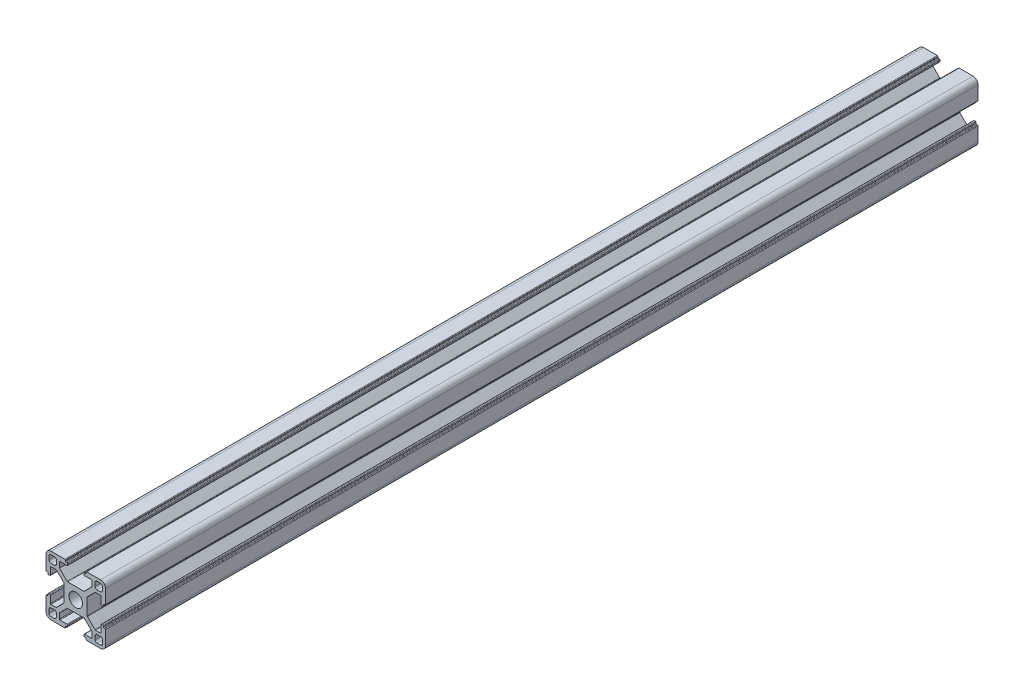
from build123d import *

# Parameters (mm, degrees)
MODEL_R         = 3.4
EXTRUDE_1_DEPTH = 440


with BuildPart() as part:
    # Model → 凸台-拉伸1 (new body)
    with BuildSketch(Plane.XY):
        with BuildLine():
            Line((127.095254839, 55.182120766), (118.855052814, 55.182120766))
            ThreePointArc((118.855052814, 55.182120766), (118.740247784, 55.204956906), (118.64292078, 55.269988732))
            Line((118.64292078, 55.269988732), (114.813021792, 59.099887719))
            ThreePointArc((114.813021792, 59.099887719), (114.747989967, 59.197214724), (114.725153827, 59.312019753))
            Line((114.725153827, 59.312019753), (114.725153827, 61.882120766))
            ThreePointArc((114.725153827, 61.882120766), (114.813021792, 62.0942528), (115.025153827, 62.182120766))
            Line((115.025153827, 62.182120766), (118.575153827, 62.182120766))
            ThreePointArc((118.575153827, 62.182120766), (118.787285861, 62.269988732), (118.875153827, 62.482120766))
            Line((118.875153827, 62.482120766), (118.875153827, 63.082120766))
            ThreePointArc((118.875153827, 63.082120766), (118.787285861, 63.2942528), (118.575153827, 63.382120766))
            Line((118.575153827, 63.382120766), (118.075153827, 63.382120766))
            ThreePointArc((118.075153827, 63.382120766), (117.863021792, 63.469988732), (117.775153827, 63.682120766))
            Line((117.775153827, 63.682120766), (117.775153827, 64.082120766))
            ThreePointArc((117.775153827, 64.082120766), (117.687285861, 64.294252801), (117.475153827, 64.382120766))
            Line((117.475153827, 64.382120766), (110.475153827, 64.382120766))
            ThreePointArc((110.475153827, 64.382120766), (108.707386874, 63.649887719), (107.975153827, 61.882120766))
            Line((107.975153827, 61.882120766), (107.975153827, 54.882120766))
            ThreePointArc((107.975153827, 54.882120766), (108.063021792, 54.669988732), (108.275153827, 54.582120766))
            Line((108.275153827, 54.582120766), (108.675153827, 54.582120766))
            ThreePointArc((108.675153827, 54.582120766), (108.887285861, 54.4942528), (108.975153827, 54.282120766))
            Line((108.975153827, 54.282120766), (108.975153827, 53.782120766))
            ThreePointArc((108.975153827, 53.782120766), (109.063021792, 53.569988732), (109.275153827, 53.482120766))
            Line((109.275153827, 53.482120766), (109.875153827, 53.482120766))
            ThreePointArc((109.875153827, 53.482120766), (110.087285861, 53.569988732), (110.175153827, 53.782120766))
            Line((110.175153827, 53.782120766), (110.175153827, 57.332120766))
            ThreePointArc((110.175153827, 57.332120766), (110.263021792, 57.5442528), (110.475153827, 57.632120766))
            Line((110.475153827, 57.632120766), (113.04525484, 57.632120766))
            ThreePointArc((113.04525484, 57.632120766), (113.160059869, 57.609284626), (113.257386874, 57.5442528))
            Line((113.257386874, 57.5442528), (117.087285861, 53.714353813))
            ThreePointArc((117.087285861, 53.714353813), (117.152317686, 53.617026808), (117.175153827, 53.502221779))
            Line((117.175153827, 53.502221779), (117.175153827, 45.262019753))
            ThreePointArc((117.175153827, 45.262019753), (117.152317686, 45.147214724), (117.087285861, 45.049887719))
            Line((117.087285861, 45.049887719), (113.257386874, 41.219988732))
            ThreePointArc((113.257386874, 41.219988732), (113.160059869, 41.154956907), (113.04525484, 41.132120766))
            Line((113.04525484, 41.132120766), (110.475153827, 41.132120766))
            ThreePointArc((110.475153827, 41.132120766), (110.263021792, 41.219988732), (110.175153827, 41.432120766))
            Line((110.175153827, 41.432120766), (110.175153827, 44.982120766))
            ThreePointArc((110.175153827, 44.982120766), (110.087285861, 45.1942528), (109.875153827, 45.282120766))
            Line((109.875153827, 45.282120766), (109.275153827, 45.282120766))
            ThreePointArc((109.275153827, 45.282120766), (109.063021792, 45.1942528), (108.975153827, 44.982120766))
            Line((108.975153827, 44.982120766), (108.975153827, 44.482120766))
            ThreePointArc((108.975153827, 44.482120766), (108.887285861, 44.269988732), (108.675153827, 44.182120766))
            Line((108.675153827, 44.182120766), (108.275153827, 44.182120766))
            ThreePointArc((108.275153827, 44.182120766), (108.063021792, 44.0942528), (107.975153827, 43.882120766))
            Line((107.975153827, 43.882120766), (107.975153827, 36.882120766))
            ThreePointArc((107.975153827, 36.882120766), (108.707386874, 35.114353813), (110.475153827, 34.382120766))
            Line((110.475153827, 34.382120766), (117.475153827, 34.382120766))
            ThreePointArc((117.475153827, 34.382120766), (117.687285861, 34.469988732), (117.775153827, 34.682120766))
            Line((117.775153827, 34.682120766), (117.775153827, 35.082120766))
            ThreePointArc((117.775153827, 35.082120766), (117.863021792, 35.2942528), (118.075153827, 35.382120766))
            Line((118.075153827, 35.382120766), (118.575153827, 35.382120766))
            ThreePointArc((118.575153827, 35.382120766), (118.787285861, 35.469988732), (118.875153827, 35.682120766))
            Line((118.875153827, 35.682120766), (118.875153827, 36.282120766))
            ThreePointArc((118.875153827, 36.282120766), (118.787285861, 36.4942528), (118.575153827, 36.582120766))
            Line((118.575153827, 36.582120766), (115.025153827, 36.582120766))
            ThreePointArc((115.025153827, 36.582120766), (114.813021792, 36.669988732), (114.725153827, 36.882120766))
            Line((114.725153827, 36.882120766), (114.725153827, 39.452221779))
            ThreePointArc((114.725153827, 39.452221779), (114.747989967, 39.567026809), (114.813021792, 39.664353813))
            Line((114.813021792, 39.664353813), (118.64292078, 43.4942528))
            ThreePointArc((118.64292078, 43.4942528), (118.740247784, 43.559284626), (118.855052814, 43.582120766))
            Line((118.855052814, 43.582120766), (127.095254839, 43.582120766))
            ThreePointArc((127.095254839, 43.582120766), (127.210059869, 43.559284626), (127.307386874, 43.4942528))
            Line((127.307386874, 43.4942528), (131.137285861, 39.664353813))
            ThreePointArc((131.137285861, 39.664353813), (131.202317686, 39.567026809), (131.225153827, 39.452221779))
            Line((131.225153827, 39.452221779), (131.225153827, 36.882120766))
            ThreePointArc((131.225153827, 36.882120766), (131.137285861, 36.669988732), (130.925153827, 36.582120766))
            Line((130.925153827, 36.582120766), (127.375153827, 36.582120766))
            ThreePointArc((127.375153827, 36.582120766), (127.163021792, 36.4942528), (127.075153827, 36.282120766))
            Line((127.075153827, 36.282120766), (127.075153827, 35.682120766))
            ThreePointArc((127.075153827, 35.682120766), (127.163021792, 35.469988732), (127.375153827, 35.382120766))
            Line((127.375153827, 35.382120766), (127.875153827, 35.382120766))
            ThreePointArc((127.875153827, 35.382120766), (128.087285861, 35.2942528), (128.175153827, 35.082120766))
            Line((128.175153827, 35.082120766), (128.175153827, 34.682120766))
            ThreePointArc((128.175153827, 34.682120766), (128.263021792, 34.469988732), (128.475153826, 34.382120766))
            Line((128.475153826, 34.382120766), (135.475153827, 34.382120766))
            ThreePointArc((135.475153827, 34.382120766), (137.24292078, 35.114353813), (137.975153827, 36.882120766))
            Line((137.975153827, 36.882120766), (137.975153827, 43.882120766))
            ThreePointArc((137.975153827, 43.882120766), (137.887285861, 44.0942528), (137.675153827, 44.182120766))
            Line((137.675153827, 44.182120766), (137.275153827, 44.182120766))
            ThreePointArc((137.275153827, 44.182120766), (137.063021792, 44.269988732), (136.975153827, 44.482120766))
            Line((136.975153827, 44.482120766), (136.975153827, 44.982120766))
            ThreePointArc((136.975153827, 44.982120766), (136.887285861, 45.1942528), (136.675153827, 45.282120766))
            Line((136.675153827, 45.282120766), (136.075153827, 45.282120766))
            ThreePointArc((136.075153827, 45.282120766), (135.863021792, 45.1942528), (135.775153827, 44.982120766))
            Line((135.775153827, 44.982120766), (135.775153827, 41.432120766))
            ThreePointArc((135.775153827, 41.432120766), (135.687285861, 41.219988732), (135.475153827, 41.132120766))
            Line((135.475153827, 41.132120766), (132.905052814, 41.132120766))
            ThreePointArc((132.905052814, 41.132120766), (132.790247784, 41.154956907), (132.692920779, 41.219988732))
            Line((132.692920779, 41.219988732), (128.863021792, 45.049887719))
            ThreePointArc((128.863021792, 45.049887719), (128.797989967, 45.147214724), (128.775153827, 45.262019753))
            Line((128.775153827, 45.262019753), (128.775153827, 53.502221779))
            ThreePointArc((128.775153827, 53.502221779), (128.797989967, 53.617026808), (128.863021792, 53.714353813))
            Line((128.863021792, 53.714353813), (132.692920779, 57.5442528))
            ThreePointArc((132.692920779, 57.5442528), (132.790247784, 57.609284626), (132.905052814, 57.632120766))
            Line((132.905052814, 57.632120766), (135.475153827, 57.632120766))
            ThreePointArc((135.475153827, 57.632120766), (135.687285861, 57.5442528), (135.775153827, 57.332120766))
            Line((135.775153827, 57.332120766), (135.775153827, 53.782120766))
            ThreePointArc((135.775153827, 53.782120766), (135.863021792, 53.569988732), (136.075153827, 53.482120766))
            Line((136.075153827, 53.482120766), (136.675153827, 53.482120766))
            ThreePointArc((136.675153827, 53.482120766), (136.887285861, 53.569988732), (136.975153827, 53.782120766))
            Line((136.975153827, 53.782120766), (136.975153827, 54.282120766))
            ThreePointArc((136.975153827, 54.282120766), (137.063021792, 54.4942528), (137.275153827, 54.582120766))
            Line((137.275153827, 54.582120766), (137.675153827, 54.582120766))
            ThreePointArc((137.675153827, 54.582120766), (137.887285861, 54.669988732), (137.975153827, 54.882120766))
            Line((137.975153827, 54.882120766), (137.975153827, 61.882120766))
            ThreePointArc((137.975153827, 61.882120766), (137.24292078, 63.649887719), (135.475153827, 64.382120766))
            Line((135.475153827, 64.382120766), (128.475153826, 64.382120766))
            ThreePointArc((128.475153826, 64.382120766), (128.263021792, 64.294252801), (128.175153827, 64.082120766))
            Line((128.175153827, 64.082120766), (128.175153827, 63.682120766))
            ThreePointArc((128.175153827, 63.682120766), (128.087285861, 63.469988732), (127.875153827, 63.382120766))
            Line((127.875153827, 63.382120766), (127.375153827, 63.382120766))
            ThreePointArc((127.375153827, 63.382120766), (127.163021792, 63.2942528), (127.075153827, 63.082120766))
            Line((127.075153827, 63.082120766), (127.075153827, 62.482120766))
            ThreePointArc((127.075153827, 62.482120766), (127.163021792, 62.269988732), (127.375153827, 62.182120766))
            Line((127.375153827, 62.182120766), (130.925153827, 62.182120766))
            ThreePointArc((130.925153827, 62.182120766), (131.137285861, 62.0942528), (131.225153827, 61.882120766))
            Line((131.225153827, 61.882120766), (131.225153827, 59.312019753))
            ThreePointArc((131.225153827, 59.312019753), (131.202317686, 59.197214724), (131.137285861, 59.099887719))
            Line((131.137285861, 59.099887719), (127.307386874, 55.269988732))
            ThreePointArc((127.307386874, 55.269988732), (127.210059869, 55.204956906), (127.095254839, 55.182120766))
        make_face()
        with Locations((122.975153827, 49.382120766)):
            Circle(MODEL_R, mode=Mode.SUBTRACT)
        with BuildLine():
            Line((113.225153827, 61.882120766), (113.225153827, 60.132120766))
            ThreePointArc((113.225153827, 60.132120766), (112.932260608, 59.425013985), (112.225153827, 59.132120766))
            Line((112.225153827, 59.132120766), (110.475153827, 59.132120766))
            ThreePointArc((110.475153827, 59.132120766), (109.768047045, 59.425013985), (109.475153827, 60.132120766))
            Line((109.475153827, 60.132120766), (109.475153827, 61.882120766))
            ThreePointArc((109.475153827, 61.882120766), (109.768047046, 62.589227547), (110.475153827, 62.882120766))
            Line((110.475153827, 62.882120766), (112.225153827, 62.882120766))
            ThreePointArc((112.225153827, 62.882120766), (112.932260608, 62.589227547), (113.225153827, 61.882120766))
        make_face(mode=Mode.SUBTRACT)
        with BuildLine():
            Line((112.225153827, 35.882120766), (110.475153827, 35.882120766))
            ThreePointArc((110.475153827, 35.882120766), (109.768047046, 36.175013985), (109.475153827, 36.882120766))
            Line((109.475153827, 36.882120766), (109.475153827, 38.632120766))
            ThreePointArc((109.475153827, 38.632120766), (109.768047045, 39.339227547), (110.475153827, 39.632120766))
            Line((110.475153827, 39.632120766), (112.225153827, 39.632120766))
            ThreePointArc((112.225153827, 39.632120766), (112.932260608, 39.339227547), (113.225153827, 38.632120766))
            Line((113.225153827, 38.632120766), (113.225153827, 36.882120766))
            ThreePointArc((113.225153827, 36.882120766), (112.932260608, 36.175013985), (112.225153827, 35.882120766))
        make_face(mode=Mode.SUBTRACT)
        with BuildLine():
            Line((132.725153827, 36.882120766), (132.725153827, 38.632120766))
            ThreePointArc((132.725153827, 38.632120766), (133.018047045, 39.339227547), (133.725153827, 39.632120766))
            Line((133.725153827, 39.632120766), (135.475153827, 39.632120766))
            ThreePointArc((135.475153827, 39.632120766), (136.182260608, 39.339227547), (136.475153827, 38.632120766))
            Line((136.475153827, 38.632120766), (136.475153827, 36.882120766))
            ThreePointArc((136.475153827, 36.882120766), (136.182260608, 36.175013985), (135.475153827, 35.882120766))
            Line((135.475153827, 35.882120766), (133.725153827, 35.882120766))
            ThreePointArc((133.725153827, 35.882120766), (133.018047045, 36.175013985), (132.725153827, 36.882120766))
        make_face(mode=Mode.SUBTRACT)
        with BuildLine():
            Line((133.725153827, 62.882120766), (135.475153827, 62.882120766))
            ThreePointArc((135.475153827, 62.882120766), (136.182260608, 62.589227547), (136.475153827, 61.882120766))
            Line((136.475153827, 61.882120766), (136.475153827, 60.132120766))
            ThreePointArc((136.475153827, 60.132120766), (136.182260608, 59.425013985), (135.475153827, 59.132120766))
            Line((135.475153827, 59.132120766), (133.725153827, 59.132120766))
            ThreePointArc((133.725153827, 59.132120766), (133.018047045, 59.425013985), (132.725153827, 60.132120766))
            Line((132.725153827, 60.132120766), (132.725153827, 61.882120766))
            ThreePointArc((132.725153827, 61.882120766), (133.018047045, 62.589227547), (133.725153827, 62.882120766))
        make_face(mode=Mode.SUBTRACT)
    extrude(amount=EXTRUDE_1_DEPTH)


solid = part.part
